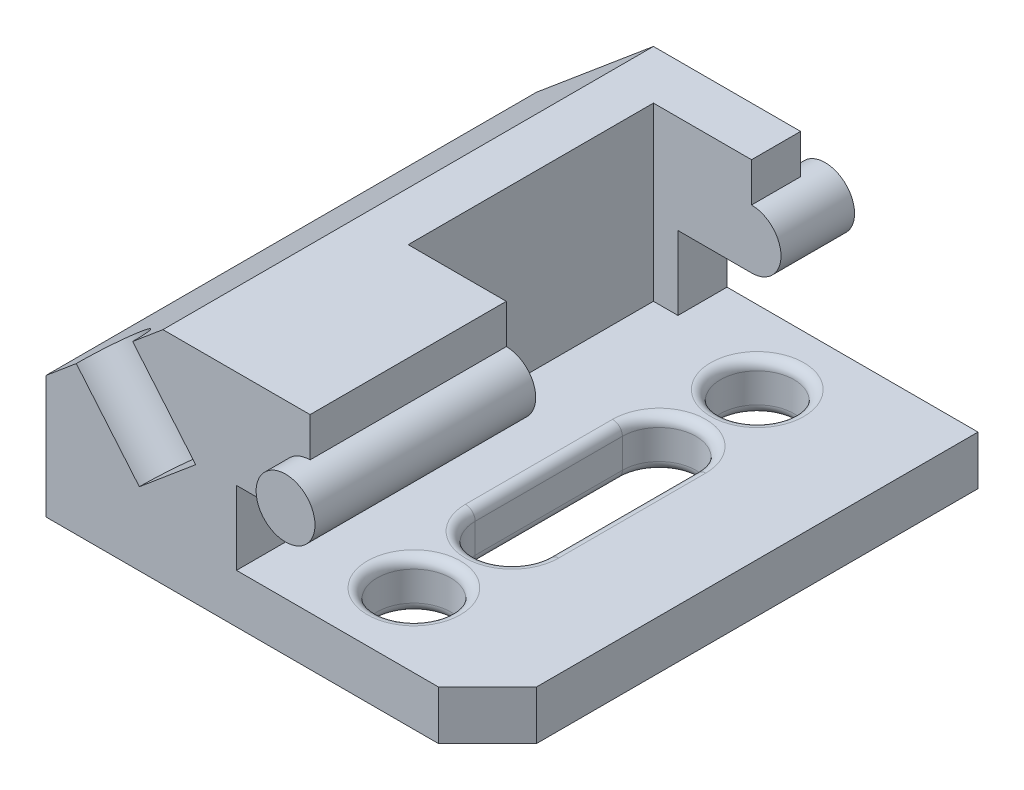
from build123d import *

# Parameters (mm, degrees)
DODANIE_WYCI_GNI_CIE1_DEPTH      = 100
SFAZOWANIE1_SIZE                 = 10
SZKIC3_R                         = 6
DODANIE_WYCI_GNI_CIE2_DEPTH      = 5
DODANIE_WYCI_GNI_CIE2_DEPTH_BACK = 105
SZKIC4_W                         = 26
SZKIC4_H                         = 50
WYTNIJ_WYCI_GNI_CIE1_DEPTH       = 35
SZKIC5_R                         = 7.5
WYTNIJ_WYCI_GNI_CIE3_DEPTH       = 11
ZAOKR_GLENIE2_R                  = 2
SZKIC6_R                         = 7.5
WYTNIJ_WYCI_GNI_CIE5_DEPTH       = 20


with BuildPart() as part:
    # Szkic2 → Dodanie-wyciągnięcie1 (new body)
    with BuildSketch(Plane.XY):
        with BuildLine():
            Line((0, 0), (90, 0))
            Line((90, 0), (90, 10))
            Line((90, 10), (38.835071852, 10))
            Line((38.835071852, 10), (38.835071852, 25))
            Line((38.835071852, 25), (53.835071852, 25))
            ThreePointArc((53.835071852, 25), (59.835071852, 31), (53.835071852, 37))
            Line((53.835071852, 37), (53.835071852, 45))
            Line((53.835071852, 45), (23.835071852, 45))
            Line((23.835071852, 45), (0, 25))
            Line((0, 25), (0, 0))
        make_face()
    extrude(amount=DODANIE_WYCI_GNI_CIE1_DEPTH)

    # Sfazowanie1
    sfazowanie1_edges = [part.edges().sort_by_distance(p)[0] for p in [
        (90, 5, 100),
    ]]
    chamfer(sfazowanie1_edges, length=SFAZOWANIE1_SIZE)

    # Szkic3 → Dodanie-wyciągnięcie2 (add, two sides)
    with BuildSketch(Plane.XY.offset(100)) as dodanie_wyci_gni_cie2_sk:
        with Locations((53.835071852, 31)):
            Circle(SZKIC3_R)
    extrude(amount=DODANIE_WYCI_GNI_CIE2_DEPTH)
    extrude(dodanie_wyci_gni_cie2_sk.sketch, amount=-DODANIE_WYCI_GNI_CIE2_DEPTH_BACK)

    # Szkic4 → Wytnij-wyciągnięcie1 (cut)
    with BuildSketch(Plane(origin=(0, 45, 0), x_dir=(1, 0, 0), z_dir=(0, 1, 0))):
        with Locations((46.835071852, -35)):
            Rectangle(SZKIC4_W, SZKIC4_H)
    extrude(amount=-WYTNIJ_WYCI_GNI_CIE1_DEPTH, mode=Mode.SUBTRACT)

    # Szkic5 → Wytnij-wyciągnięcie3 (cut, through all)
    with BuildSketch(Plane(origin=(0, 10, 0), x_dir=(1, 0, 0), z_dir=(0, 1, 0))):
        with Locations((60, -15)):
            Circle(SZKIC5_R)
        with Locations((60, -85)):
            Circle(SZKIC5_R)
        with BuildLine():
            Line((52.5, -35), (52.5, -65))
            ThreePointArc((52.5, -65), (60, -72.5), (67.5, -65))
            Line((67.5, -65), (67.5, -35))
            ThreePointArc((67.5, -35), (60, -27.5), (52.5, -35))
        make_face()
    extrude(amount=-WYTNIJ_WYCI_GNI_CIE3_DEPTH, mode=Mode.SUBTRACT)

    # Zaokrąglenie2
    zaokr_glenie2_edges = [part.edges().sort_by_distance(p)[0] for p in [
        (52.5, 0, 15),
        (52.5, 10, 15),
        (52.5, 0, 85),
        (52.5, 10, 85),
        (60, 0, 27.5),
        (67.5, 0, 50),
        (60, 0, 72.5),
        (52.5, 0, 50),
        (60, 10, 27.5),
        (52.5, 10, 50),
        (60, 10, 72.5),
        (67.5, 10, 50),
    ]]
    fillet(zaokr_glenie2_edges, radius=ZAOKR_GLENIE2_R)

    # Szkic6 → Wytnij-wyciągnięcie5 (cut)
    with BuildSketch(Plane(origin=(-12.310096913, 14.670602221, 0), x_dir=(0.766044443, 0.64278761, 0), z_dir=(-0.64278761, 0.766044443, 0))):
        with Locations((31.626928511, -100)):
            Circle(SZKIC6_R)
    extrude(amount=-WYTNIJ_WYCI_GNI_CIE5_DEPTH, mode=Mode.SUBTRACT)


solid = part.part
